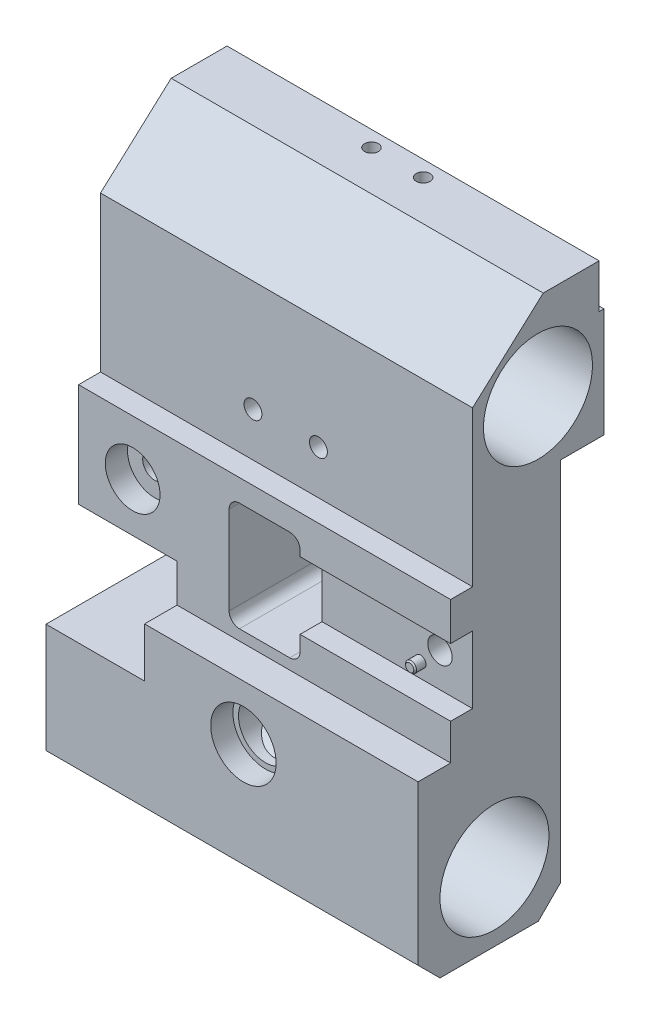
from build123d import *

# Parameters (mm, degrees)
SKETCH1_R                = 15.83
BOSS_EXTRUDE1_DEPTH      = 54
BOSS_EXTRUDE1_DEPTH_BACK = 54
SKETCH2_R                = 7.875
SKETCH2_R_2              = 2.6
SKETCH2_R_3              = 3.525
SKETCH2_R_4              = 3.55
SKETCH2_W                = 28.6
SKETCH2_H                = 25.4
CUT_EXTRUDE1_DEPTH       = 42.28
SKETCH3_W                = 43.7
SKETCH3_H                = 19.52
CUT_EXTRUDE2_DEPTH       = 6.36
SKETCH4_R                = 1.585
BOSS_EXTRUDE2_DEPTH      = 3.15
SKETCH10_R               = 1.585
CUT_EXTRUDE6_DEPTH       = 20
SKETCH11_R               = 5.5
SKETCH11_R_2             = 3.525
SKETCH11_R_3             = 5.42
CUT_EXTRUDE7_DEPTH       = 6.56
CHAMFER1_SIZE            = 0.4
SKETCH5_R                = 7.945
CUT_EXTRUDE3_DEPTH       = 6.44
SKETCH6_R                = 9.495
CUT_EXTRUDE4_DEPTH       = 6.44
SKETCH7_W                = 8.77
SKETCH7_H                = 34.96
BOSS_EXTRUDE3_DEPTH      = 3.1
SKETCH8_R                = 2
CUT_EXTRUDE5_DEPTH       = 15
SKETCH11_3_R             = 4.55
SKETCH11_3_R_2           = 2.6
CUT_EXTRUDE8_DEPTH       = 5.45
SKETCH12_R               = 9.475
CUT_EXTRUDE9_DEPTH       = 5.15
SKETCH13_R               = 2
CUT_EXTRUDE10_DEPTH      = 10
SKETCH14_R               = 2
CUT_EXTRUDE11_DEPTH      = 10
SKETCH15_R               = 2
CUT_EXTRUDE12_DEPTH      = 44.48
SKETCH16_R               = 2
CUT_EXTRUDE13_DEPTH      = 25
CUT_EXTRUDE15_REACH      = 43.28
SKETCH18_R               = 2
SKETCH19_R               = 2.3
CUT_EXTRUDE16_DEPTH      = 20


with BuildPart() as part:
    # Sketch1 → Boss-Extrude1 (new body, two sides)
    with BuildSketch(Plane(origin=(0, 0, 0), x_dir=(0, 0, -1), z_dir=(1, 0, 0))) as boss_extrude1_sk:
        Polygon((14.15, 137.2), (30.37, 137.2), (30.37, 124.41), (31.79, 124.41), (31.79, 92.72), (19.1, 92.72), (19.1, -13.636038969), (12.736038969, -20), (-15.816038969, -20), (-22.18, -13.636038969), (-22.18, 32.5), (-12.73, 32.5), (-12.73, 73.61), (-6.36, 73.61), (-6.36, 118.61), align=None)
        Circle(SKETCH1_R, mode=Mode.SUBTRACT)
        with Locations((12.625, 111.985)):
            Circle(SKETCH1_R, mode=Mode.SUBTRACT)
    extrude(amount=BOSS_EXTRUDE1_DEPTH)
    extrude(boss_extrude1_sk.sketch, amount=-BOSS_EXTRUDE1_DEPTH_BACK)

    # Sketch2 → Cut-Extrude1 (cut, through all)
    with BuildSketch(Plane(origin=(0, 0, -19.1), x_dir=(-1, 0, 0), z_dir=(0, 0, -1))):
        with Locations((-3.3, 16.595)):
            Circle(SKETCH2_R)
        with Locations((-9.25, 86.37)):
            Circle(SKETCH2_R_2)
        with Locations((9.75, 86.37)):
            Circle(SKETCH2_R_2)
        with Locations((38.3, 57.72)):
            Circle(SKETCH2_R_3)
        with Locations((-44.55, 52.92)):
            Circle(SKETCH2_R_4)
        with BuildLine():
            Line((-7.3, 67.2), (7.3, 67.2))
            ThreePointArc((7.3, 67.2), (9.421320344, 66.321320344), (10.3, 64.2))
            Line((10.3, 64.2), (10.3, 38.6))
            ThreePointArc((10.3, 38.6), (9.421320344, 36.478679656), (7.3, 35.6))
            Line((7.3, 35.6), (-7.3, 35.6))
            ThreePointArc((-7.3, 35.6), (-9.421320344, 36.478679656), (-10.3, 38.6))
            Line((-10.3, 38.6), (-10.3, 64.2))
            ThreePointArc((-10.3, 64.2), (-9.421320344, 66.321320344), (-7.3, 67.2))
        make_face()
        with Locations((39.7, 30.83)):
            Rectangle(SKETCH2_W, SKETCH2_H)
    extrude(amount=-CUT_EXTRUDE1_DEPTH, mode=Mode.SUBTRACT)

    # Sketch3 → Cut-Extrude2 (cut)
    with BuildSketch(Plane.XY.offset(12.73)):
        with Locations((32.15, 52.76)):
            Rectangle(SKETCH3_W, SKETCH3_H)
    extrude(amount=-CUT_EXTRUDE2_DEPTH, mode=Mode.SUBTRACT)

    # Sketch4 → Boss-Extrude2 (add)
    with BuildSketch(Plane.XY.offset(6.37)):
        with Locations((38.915, 47.335)):
            Circle(SKETCH4_R)
    extrude(amount=BOSS_EXTRUDE2_DEPTH)

    # Sketch10 → Cut-Extrude6 (cut)
    with BuildSketch(Plane(origin=(0, 0, -19.1), x_dir=(-1, 0, 0), z_dir=(0, 0, -1))):
        with Locations((-38.915, 47.335)):
            Circle(SKETCH10_R)
    extrude(amount=-CUT_EXTRUDE6_DEPTH, mode=Mode.SUBTRACT)

    # Sketch11 → Cut-Extrude7 (cut)
    with BuildSketch(Plane(origin=(0, 0, -19.1), x_dir=(-1, 0, 0), z_dir=(0, 0, -1))):
        with Locations((38.3, 57.72)):
            Circle(SKETCH11_R)
        with Locations((38.3, 57.72)):
            Circle(SKETCH11_R_2, mode=Mode.SUBTRACT)
        with Locations((-44.55, 52.92)):
            Circle(SKETCH11_R_3)
    extrude(amount=-CUT_EXTRUDE7_DEPTH, mode=Mode.SUBTRACT)

    # Chamfer1
    chamfer1_edges = [part.edges().sort_by_distance(p)[0] for p in [
        (37.33, 47.335, 9.52),
    ]]
    chamfer(chamfer1_edges, length=CHAMFER1_SIZE)

    # Sketch5 → Cut-Extrude3 (cut)
    with BuildSketch(Plane.XY.offset(12.73)):
        with Locations((-38.3, 57.72)):
            Circle(SKETCH5_R)
    extrude(amount=-CUT_EXTRUDE3_DEPTH, mode=Mode.SUBTRACT)

    # Sketch6 → Cut-Extrude4 (cut)
    with BuildSketch(Plane.XY.offset(22.18)):
        with Locations((3.3, 16.595)):
            Circle(SKETCH6_R)
    extrude(amount=-CUT_EXTRUDE4_DEPTH, mode=Mode.SUBTRACT)

    # Sketch7 → Boss-Extrude3 (add)
    with BuildSketch(Plane(origin=(0, 0, -19.1), x_dir=(-1, 0, 0), z_dir=(0, 0, -1))):
        with Locations((21.015, 16.59)):
            Rectangle(SKETCH7_W, SKETCH7_H)
    extrude(amount=BOSS_EXTRUDE3_DEPTH)

    # Sketch8 → Cut-Extrude5 (cut)
    with BuildSketch(Plane(origin=(0, 0, -22.2), x_dir=(-1, 0, 0), z_dir=(0, 0, -1))):
        with Locations((21.4, 29.135)):
            Circle(SKETCH8_R)
        with Locations((21.4, 3.82)):
            Circle(SKETCH8_R)
    extrude(amount=-CUT_EXTRUDE5_DEPTH, mode=Mode.SUBTRACT)

    # Sketch11_3 → Cut-Extrude8 (cut)
    with BuildSketch(Plane(origin=(0, 0, -19.1), x_dir=(-1, 0, 0), z_dir=(0, 0, -1))):
        with Locations((-9.25, 86.37)):
            Circle(SKETCH11_3_R)
        with Locations((-9.25, 86.37)):
            Circle(SKETCH11_3_R_2, mode=Mode.SUBTRACT)
        with Locations((9.75, 86.37)):
            Circle(SKETCH11_3_R)
        with Locations((9.75, 86.37)):
            Circle(SKETCH11_3_R_2, mode=Mode.SUBTRACT)
    extrude(amount=-CUT_EXTRUDE8_DEPTH, mode=Mode.SUBTRACT)

    # Sketch12 → Cut-Extrude9 (cut)
    with BuildSketch(Plane(origin=(0, 0, -19.1), x_dir=(-1, 0, 0), z_dir=(0, 0, -1))):
        with Locations((-3.3, 16.595)):
            Circle(SKETCH12_R)
    extrude(amount=-CUT_EXTRUDE9_DEPTH, mode=Mode.SUBTRACT)

    # Sketch13 → Cut-Extrude10 (cut)
    with BuildSketch(Plane(origin=(0, 0, -19.1), x_dir=(-1, 0, 0), z_dir=(0, 0, -1))):
        with Locations((-13.5, 73.72)):
            Circle(SKETCH13_R)
        with Locations((13.2, 73.72)):
            Circle(SKETCH13_R)
        with Locations((-13.5, 41.72)):
            Circle(SKETCH13_R)
        with Locations((13.2, 41.72)):
            Circle(SKETCH13_R)
        with Locations((20.3, 41.72)):
            Circle(SKETCH13_R)
        with Locations((-21, 41.92)):
            Circle(SKETCH13_R)
    extrude(amount=-CUT_EXTRUDE10_DEPTH, mode=Mode.SUBTRACT)

    # Sketch14 → Cut-Extrude11 (cut)
    with BuildSketch(Plane(origin=(0, 0, -30.37), x_dir=(-1, 0, 0), z_dir=(0, 0, -1))):
        with Locations((-0.2, 130.91)):
            Circle(SKETCH14_R)
    extrude(amount=-CUT_EXTRUDE11_DEPTH, mode=Mode.SUBTRACT)

    # Sketch15 → Cut-Extrude12 (cut)
    with BuildSketch(Plane(origin=(0, 137.2, 0), x_dir=(-1, 0, 0), z_dir=(0, 1, 0))):
        with Locations((7.5, -25.79)):
            Circle(SKETCH15_R)
        with Locations((-7.5, -25.79)):
            Circle(SKETCH15_R)
    extrude(amount=-CUT_EXTRUDE12_DEPTH, mode=Mode.SUBTRACT)

    # Sketch16 → Cut-Extrude13 (cut)
    with BuildSketch(Plane.ZY.offset(25.4)):
        with Locations((7.582692482, 28.581604623)):
            Circle(SKETCH16_R)
        with Locations((-8.63178952, 32.368608369)):
            Circle(SKETCH16_R)
    extrude(amount=-CUT_EXTRUDE13_DEPTH, mode=Mode.SUBTRACT)

    # Sketch18 → Cut-Extrude15 (cut, up to next)
    with BuildSketch(Plane(origin=(0, 0, -19.1), x_dir=(-1, 0, 0), z_dir=(0, 0, -1)), mode=Mode.PRIVATE) as cut_extrude15_sk1:
        with Locations((7.5, -7.027)):
            Circle(SKETCH18_R)
    cut_extrude15_tool1 = extrude(cut_extrude15_sk1.sketch, amount=-CUT_EXTRUDE15_REACH, mode=Mode.PRIVATE) & part.part
    add(cut_extrude15_tool1.solids().sort_by_distance((-7.5, -7.027, -19.1))[0], mode=Mode.SUBTRACT)
    # Sketch18 → Cut-Extrude15 (cut, up to next)
    with BuildSketch(Plane(origin=(0, 0, -19.1), x_dir=(-1, 0, 0), z_dir=(0, 0, -1)), mode=Mode.PRIVATE) as cut_extrude15_sk2:
        with Locations((-7.5, -9.027000817)):
            Circle(SKETCH18_R)
    cut_extrude15_tool2 = extrude(cut_extrude15_sk2.sketch, amount=-CUT_EXTRUDE15_REACH, mode=Mode.PRIVATE) & part.part
    add(cut_extrude15_tool2.solids().sort_by_distance((7.5, -9.027001, -19.1))[0], mode=Mode.SUBTRACT)

    # Sketch19 → Cut-Extrude16 (cut)
    with BuildSketch(Plane(origin=(0, 0, -19.1), x_dir=(-1, 0, 0), z_dir=(0, 0, -1))):
        with Locations((-26.922, 67.473)):
            Circle(SKETCH19_R)
        with Locations((-26.922, 26.298)):
            Circle(SKETCH19_R)
    extrude(amount=-CUT_EXTRUDE16_DEPTH, mode=Mode.SUBTRACT)


solid = part.part
